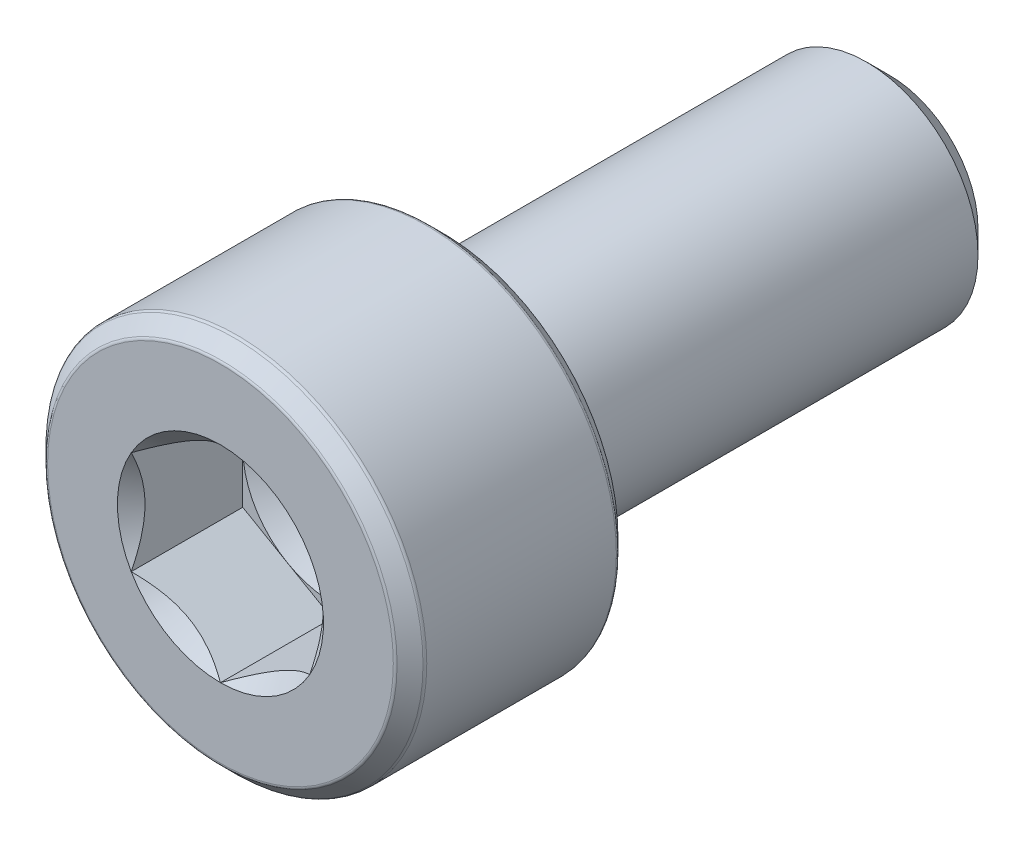
from build123d import *

# Parameters (mm, degrees)
CUT_EXTRUDE1_DEPTH = 2.5


with BuildPart() as part:
    # Sketch3 → Revolve1 (revolve)
    with BuildSketch(Plane(origin=(0, 0, 0), x_dir=(0, 0, -1), z_dir=(1, 0, 0)), mode=Mode.PRIVATE) as revolve1_sk:
        with BuildLine():
            Line((-7.5, 3.874791847), (-7.5, 2))
            Line((-7.5, 2), (-5, 2))
            Line((-5, 2), (-5, 0))
            Line((-5, 0), (7.5, 0))
            Line((7.5, 0), (7.5, 1.980384758))
            Line((7.5, 1.980384758), (6.980384758, 2.5))
            Line((6.980384758, 2.5), (-2.5, 2.5))
            Line((-2.5, 2.5), (-2.5, 3.874791847))
            ThreePointArc((-2.5, 3.874791847), (-2.50647024, 3.907319939), (-2.524895924, 3.934895924))
            Line((-2.524895924, 3.934895924), (-2.815104076, 4.225104076))
            ThreePointArc((-2.815104076, 4.225104076), (-2.842680061, 4.24352976), (-2.875208153, 4.25))
            Line((-2.875208153, 4.25), (-7.124791847, 4.25))
            ThreePointArc((-7.124791847, 4.25), (-7.157319939, 4.24352976), (-7.184895924, 4.225104076))
            Line((-7.184895924, 4.225104076), (-7.475104076, 3.934895924))
            ThreePointArc((-7.475104076, 3.934895924), (-7.49352976, 3.907319939), (-7.5, 3.874791847))
        make_face()
    revolve(revolve1_sk.sketch.rotate(Axis((0, 0, 7.5), (0, 0, -1)), 90), axis=Axis((0, 0, 7.5), (0, 0, -1)))

    # Sketch4 → Cut-Extrude1 (cut)
    with BuildSketch(Plane.XY.offset(7.5)):
        Polygon((0, 2.309401077), (-2, 1.154700538), (-2, -1.154700538), (0, -2.309401077), (2, -1.154700538), (2, 1.154700538), align=None)
    extrude(amount=-CUT_EXTRUDE1_DEPTH, mode=Mode.SUBTRACT)

    # Cut-Extrude2 cone 1 section (through the dimple's axis) → Cut-Extrude2 (revolve, cut)
    with BuildSketch(Plane(origin=(0, 0, 7.5), x_dir=(0, -1, 0), z_dir=(1, 0, 0))):
        Polygon((0, 0), (2.309401077, 0), (0, 2.309401077), align=None)
    revolve(axis=Axis((0, 0, 7.5), (0, 0, -1)), mode=Mode.SUBTRACT)

    # Cut-Extrude3 cone 1 section (through the dimple's axis) → Cut-Extrude3 (revolve, cut)
    with BuildSketch(Plane(origin=(0, 0, 5), x_dir=(0, -1, 0), z_dir=(1, 0, 0))):
        Polygon((0, 0), (2, 0), (0, 1.154700538), align=None)
    revolve(axis=Axis((0, 0, 5), (0, 0, -1)), mode=Mode.SUBTRACT)


solid = part.part
